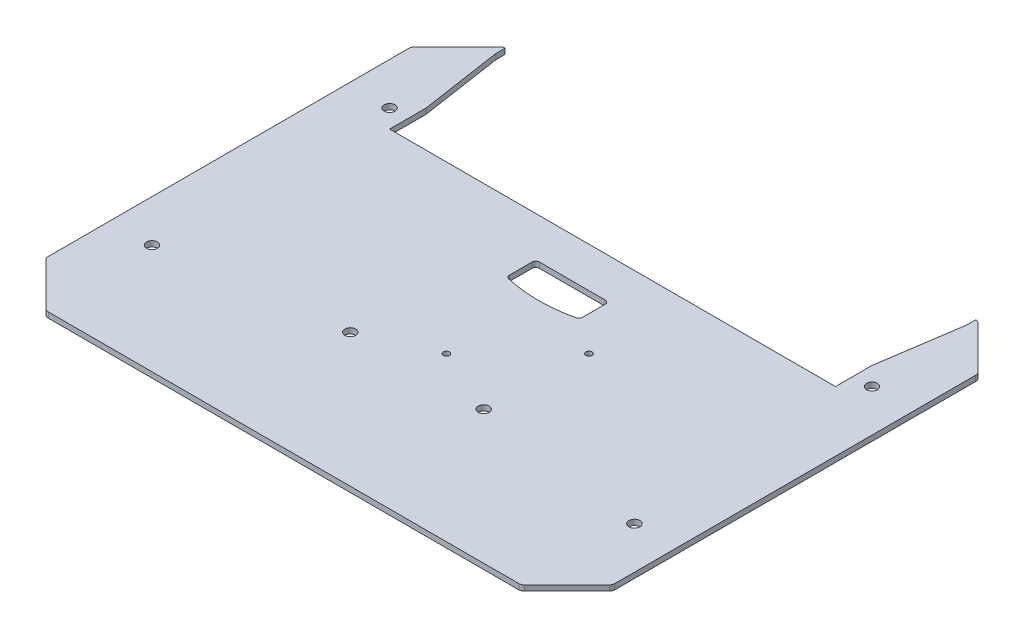
from build123d import *

# Parameters (mm, degrees)
BOSS_EXTRU_1_DEPTH      = 3
CONG_1_R                = 3
ESQUISSE2_R             = 3
PER_AGE_PROFIL_DEPTH    = 4
ESQUISSE3_R             = 3
ENL_V_MAT_EXTRU_1_DEPTH = 4
ENL_V_MAT_EXTRU_3_REACH = 5
ESQUISSE5_R             = 1.7
ENL_V_MAT_EXTRU_4_REACH = 5
CONG_2_R                = 2
ENL_V_MAT_EXTRU_2_REACH = 5


with BuildPart() as part:
    # Esquisse1 → Boss.-Extru.1 (new body)
    with BuildSketch(Plane(origin=(0, 0, 0), x_dir=(1, 0, 0), z_dir=(0, 1, 0))):
        Polygon((-130, 125), (130, 125), (155, 100), (155, -100), (130, -125), (-130, -125), (-155, -100), (-155, 100), align=None)
    extrude(amount=BOSS_EXTRU_1_DEPTH)

    # Congé1
    cong_1_edges = [part.edges().sort_by_distance(p)[0] for p in [
        (155, 1.5, -100),
        (155, 1.5, 100),
        (130, 1.5, 125),
        (-130, 1.5, 125),
        (-155, 1.5, 100),
        (-155, 1.5, -100),
        (-130, 1.5, -125),
        (130, 1.5, -125),
    ]]
    fillet(cong_1_edges, radius=CONG_1_R)

    # Esquisse2 → Perçage Profilé (cut, through all)
    with BuildSketch(Plane(origin=(0, 3, 0), x_dir=(1, 0, 0), z_dir=(0, 1, 0))):
        with Locations((-132, 65)):
            Circle(ESQUISSE2_R)
        with Locations((-132, -65)):
            Circle(ESQUISSE2_R)
        with Locations((132, -65)):
            Circle(ESQUISSE2_R)
        with Locations((132, 65)):
            Circle(ESQUISSE2_R)
    extrude(amount=-PER_AGE_PROFIL_DEPTH, mode=Mode.SUBTRACT)

    # Esquisse3 → Enlèv. mat.-Extru.1 (cut, through all)
    with BuildSketch(Plane(origin=(0, 3, 0), x_dir=(1, 0, 0), z_dir=(0, 1, 0))):
        with Locations((-36.5, -52)):
            Circle(ESQUISSE3_R)
        with Locations((36.5, -52)):
            Circle(ESQUISSE3_R)
    extrude(amount=-ENL_V_MAT_EXTRU_1_DEPTH, mode=Mode.SUBTRACT)

    # Esquisse5 → Enlèv. mat.-Extru.3 (cut, up to next)
    with BuildSketch(Plane(origin=(0, 3, 0), x_dir=(1, 0, 0), z_dir=(0, 1, 0)), mode=Mode.PRIVATE) as enl_v_mat_extru_3_sk1:
        with Locations((0, -35.89)):
            Circle(ESQUISSE5_R)
    enl_v_mat_extru_3_tool1 = extrude(enl_v_mat_extru_3_sk1.sketch, amount=-ENL_V_MAT_EXTRU_3_REACH, mode=Mode.PRIVATE) & part.part
    add(enl_v_mat_extru_3_tool1.solids().sort_by_distance((0, 3, 35.89))[0], mode=Mode.SUBTRACT)
    # Esquisse5 → Enlèv. mat.-Extru.3 (cut, up to next)
    with BuildSketch(Plane(origin=(0, 3, 0), x_dir=(1, 0, 0), z_dir=(0, 1, 0)), mode=Mode.PRIVATE) as enl_v_mat_extru_3_sk2:
        with Locations((39, 3.11)):
            Circle(ESQUISSE5_R)
    enl_v_mat_extru_3_tool2 = extrude(enl_v_mat_extru_3_sk2.sketch, amount=-ENL_V_MAT_EXTRU_3_REACH, mode=Mode.PRIVATE) & part.part
    add(enl_v_mat_extru_3_tool2.solids().sort_by_distance((39, 3, -3.11))[0], mode=Mode.SUBTRACT)

    # Esquisse6 → Enlèv. mat.-Extru.4 (cut, up to next)
    with BuildSketch(Plane(origin=(0, 3, 0), x_dir=(1, 0, 0), z_dir=(0, 1, 0)), mode=Mode.PRIVATE) as enl_v_mat_extru_4_sk1:
        with BuildLine():
            Line((-20, 33), (20, 33))
            Line((20, 33), (20, 17))
            ThreePointArc((20, 17), (0, 14.523581408), (-20, 17))
            Line((-20, 17), (-20, 33))
        make_face()
    enl_v_mat_extru_4_tool1 = extrude(enl_v_mat_extru_4_sk1.sketch, amount=-ENL_V_MAT_EXTRU_4_REACH, mode=Mode.PRIVATE) & part.part
    add(enl_v_mat_extru_4_tool1.solids().sort_by_distance((0, 3, -24.156632))[0], mode=Mode.SUBTRACT)

    # Congé2
    cong_2_edges = [part.edges().sort_by_distance(p)[0] for p in [
        (-20, 1.5, -17),
        (-20, 1.5, -33),
        (20, 1.5, -33),
        (20, 1.5, -17),
    ]]
    fillet(cong_2_edges, radius=CONG_2_R)

    # Esquisse4 → Enlèv. mat.-Extru.2 (cut, up to next)
    with BuildSketch(Plane(origin=(0, 3, 0), x_dir=(1, 0, 0), z_dir=(0, 1, 0)), mode=Mode.PRIVATE) as enl_v_mat_extru_2_sk1:
        Polygon((122, 55), (-122, 55), (-122, 75), (-128.757359313, 120), (-128.757359313, 125), (128.757359313, 125), (128.757359313, 120), (122, 75), align=None)
    enl_v_mat_extru_2_tool1 = extrude(enl_v_mat_extru_2_sk1.sketch, amount=-ENL_V_MAT_EXTRU_2_REACH, mode=Mode.PRIVATE) & part.part
    add(enl_v_mat_extru_2_tool1.solids().sort_by_distance((0, 3, -90.387205))[0], mode=Mode.SUBTRACT)


solid = part.part
